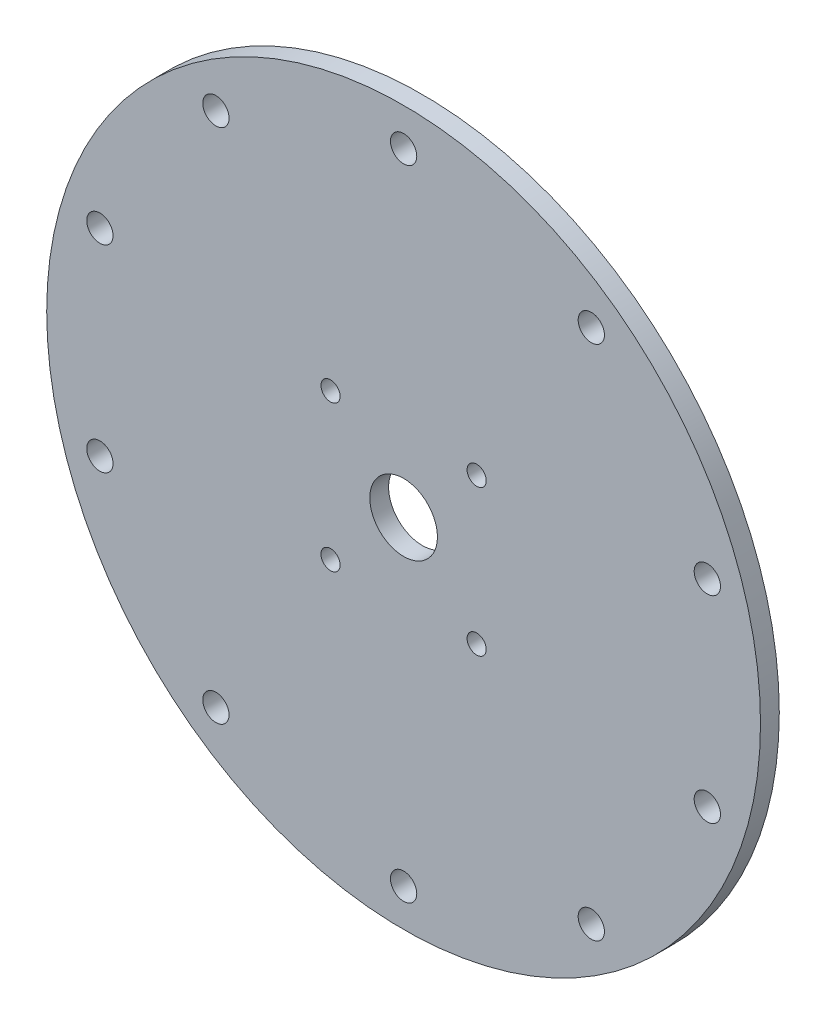
from build123d import *

# Parameters (mm, degrees)
IZIM1_R                     = 190
IZIM1_R_2                   = 7
IZIM1_R_3                   = 18
IZIM1_R_4                   = 5.1
Y_KSEKLIK_EKSTR_ZYON1_DEPTH = 10


with BuildPart() as part:
    # Çizim1 → Yükseklik-Ekstrüzyon1 (new body)
    with BuildSketch(Plane.XY):
        Circle(IZIM1_R)
        with Locations((0, 170)):
            Circle(IZIM1_R_2, mode=Mode.SUBTRACT)
        with Locations((-99.92349289, 137.532889044)):
            Circle(IZIM1_R_2, mode=Mode.SUBTRACT)
        with Locations((-161.67960777, 52.532889044)):
            Circle(IZIM1_R_2, mode=Mode.SUBTRACT)
        with Locations((-161.67960777, -52.532889044)):
            Circle(IZIM1_R_2, mode=Mode.SUBTRACT)
        with Locations((-99.92349289, -137.532889044)):
            Circle(IZIM1_R_2, mode=Mode.SUBTRACT)
        with Locations((0, -170)):
            Circle(IZIM1_R_2, mode=Mode.SUBTRACT)
        with Locations((99.92349289, -137.532889044)):
            Circle(IZIM1_R_2, mode=Mode.SUBTRACT)
        with Locations((161.67960777, -52.532889044)):
            Circle(IZIM1_R_2, mode=Mode.SUBTRACT)
        with Locations((161.67960777, 52.532889044)):
            Circle(IZIM1_R_2, mode=Mode.SUBTRACT)
        with Locations((99.92349289, 137.532889044)):
            Circle(IZIM1_R_2, mode=Mode.SUBTRACT)
        Circle(IZIM1_R_3, mode=Mode.SUBTRACT)
        with Locations((-38.890872965, 38.890872965)):
            Circle(IZIM1_R_4, mode=Mode.SUBTRACT)
        with Locations((38.890872965, 38.890872965)):
            Circle(IZIM1_R_4, mode=Mode.SUBTRACT)
        with Locations((38.890872965, -38.890872965)):
            Circle(IZIM1_R_4, mode=Mode.SUBTRACT)
        with Locations((-38.890872965, -38.890872965)):
            Circle(IZIM1_R_4, mode=Mode.SUBTRACT)
    extrude(amount=Y_KSEKLIK_EKSTR_ZYON1_DEPTH)


solid = part.part
